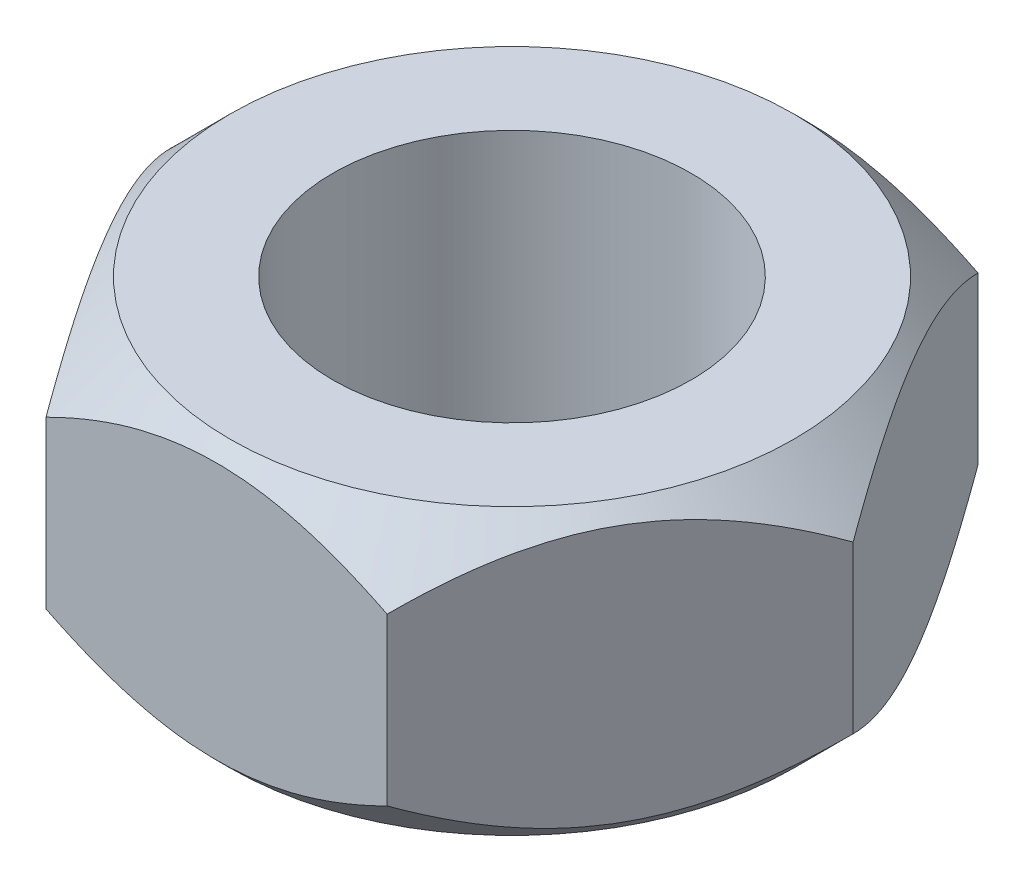
from build123d import *

# Parameters (mm, degrees)
SKETCH1_R           = 3.775
BOSS_EXTRUDE1_DEPTH = 6


with BuildPart() as part:
    # Sketch1 → Boss-Extrude1 (new body)
    with BuildSketch(Plane(origin=(0, 0, 0), x_dir=(1, 0, 0), z_dir=(0, 1, 0))):
        Polygon((-7.188010851, 0), (-3.594005426, -6.225), (3.594005426, -6.225), (7.188010851, 0), (3.594005426, 6.225), (-3.594005426, 6.225), align=None)
        Circle(SKETCH1_R, mode=Mode.SUBTRACT)
    extrude(amount=BOSS_EXTRUDE1_DEPTH)

    # Sketch5 → Cut-Revolve1 (revolve, cut)
    with BuildSketch(Plane.XY):
        Polygon((-5.938010851, 6), (-7.188010851, 6), (-7.188010851, 4.75), align=None)
        Polygon((-5.938010851, 0), (-7.188010851, 0), (-7.188010851, 1.25), align=None)
    revolve(axis=Axis((0, 0, 0), (0, 1, 0)), mode=Mode.SUBTRACT)


solid = part.part
